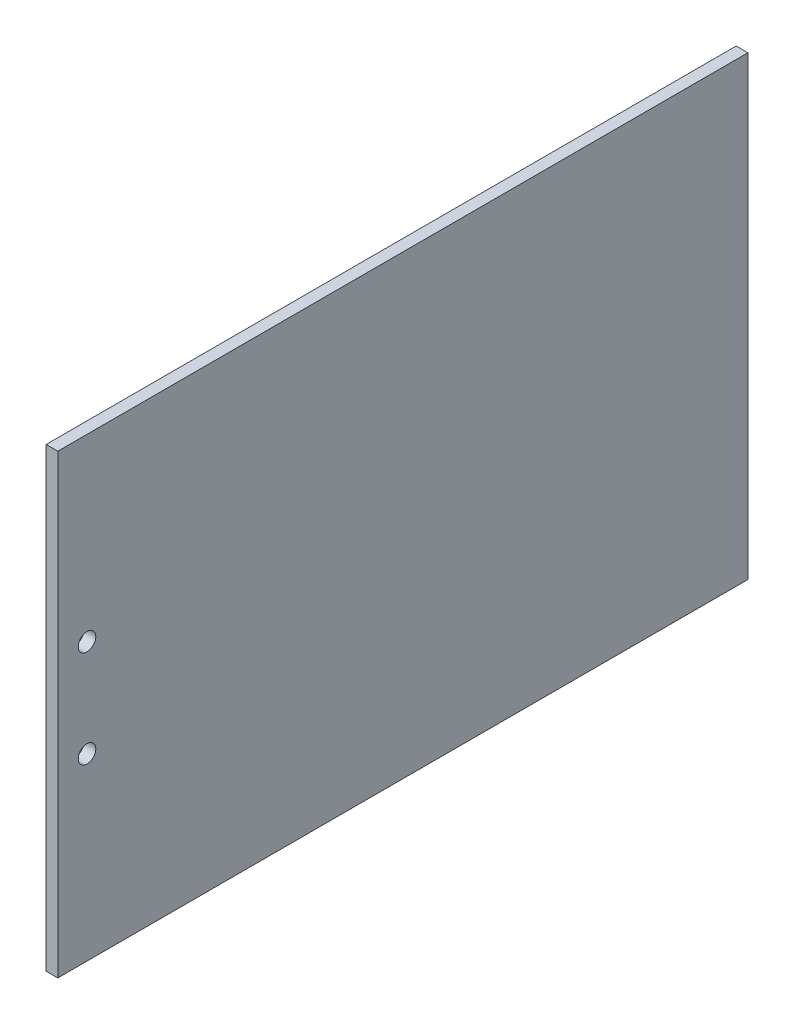
from build123d import *

# Parameters (mm, degrees)
SKETCH1_W           = 149.86
SKETCH1_H           = 99.06
SKETCH1_R           = 1.905
BOSS_EXTRUDE1_DEPTH = 2.54


with BuildPart() as part:
    # Sketch1 → Boss-Extrude1 (new body)
    with BuildSketch(Plane(origin=(0, 0, 0), x_dir=(0, 0, -1), z_dir=(1, 0, 0))):
        Rectangle(SKETCH1_W, SKETCH1_H)
        with Locations((-68.58, 10.541)):
            Circle(SKETCH1_R, mode=Mode.SUBTRACT)
        with Locations((-68.58, -10.541)):
            Circle(SKETCH1_R, mode=Mode.SUBTRACT)
    extrude(amount=BOSS_EXTRUDE1_DEPTH)


solid = part.part
